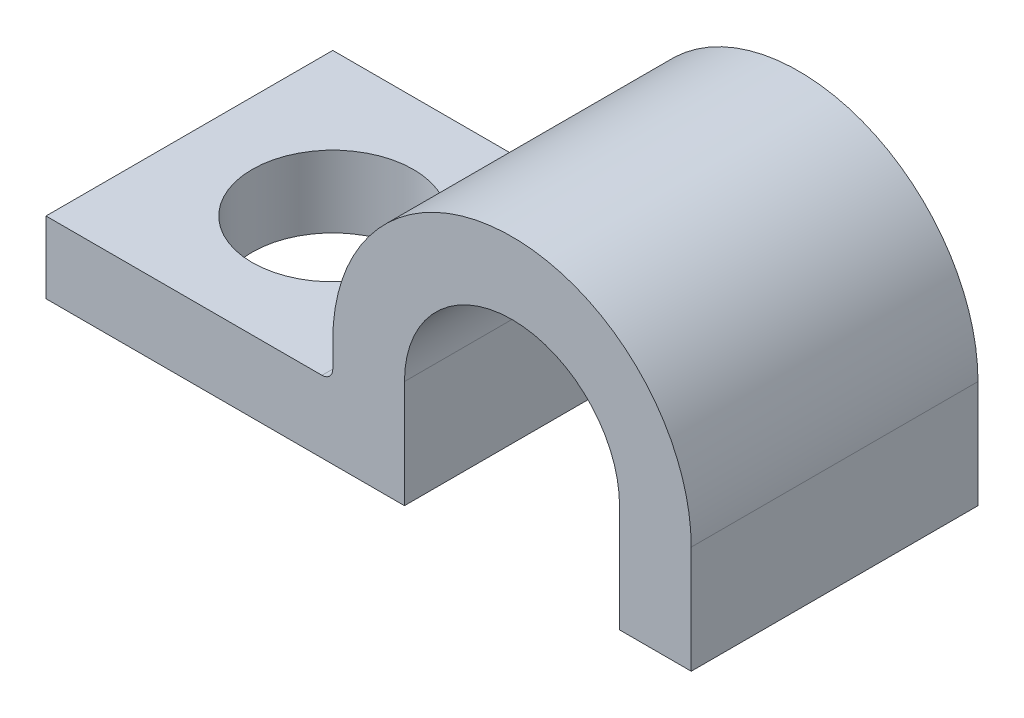
from build123d import *

# Parameters (mm, degrees)
BASE_EXTRUSION_DEPTH    = 8
ESQUISSE2_R             = 2.25
ENL_V_MAT_EXTRU_1_DEPTH = 3
CONG_1_R                = 0.3


with BuildPart() as part:
    # Esquisse1 → Base-Extrusion (new body)
    with BuildSketch(Plane.XY):
        with BuildLine():
            Line((0, 0), (10, 0))
            Line((10, 0), (10, 3))
            ThreePointArc((10, 3), (13, 6), (16, 3))
            Line((16, 3), (16, 0))
            Line((16, 0), (18, 0))
            Line((18, 0), (18, 3))
            ThreePointArc((18, 3), (13, 8), (8, 3))
            Line((8, 3), (8, 2))
            Line((8, 2), (0, 2))
            Line((0, 2), (0, 0))
        make_face()
    extrude(amount=BASE_EXTRUSION_DEPTH)

    # Esquisse2 → Enlèv. mat.-Extru.1 (cut, through all)
    with BuildSketch(Plane(origin=(0, 2, 0), x_dir=(-1, 0, 0), z_dir=(0, 1, 0))):
        with Locations((-4, 4)):
            Circle(ESQUISSE2_R)
    extrude(amount=-ENL_V_MAT_EXTRU_1_DEPTH, mode=Mode.SUBTRACT)

    # Congé1
    cong_1_edges = [part.edges().sort_by_distance(p)[0] for p in [
        (8, 2, 4),
    ]]
    fillet(cong_1_edges, radius=CONG_1_R)


solid = part.part
